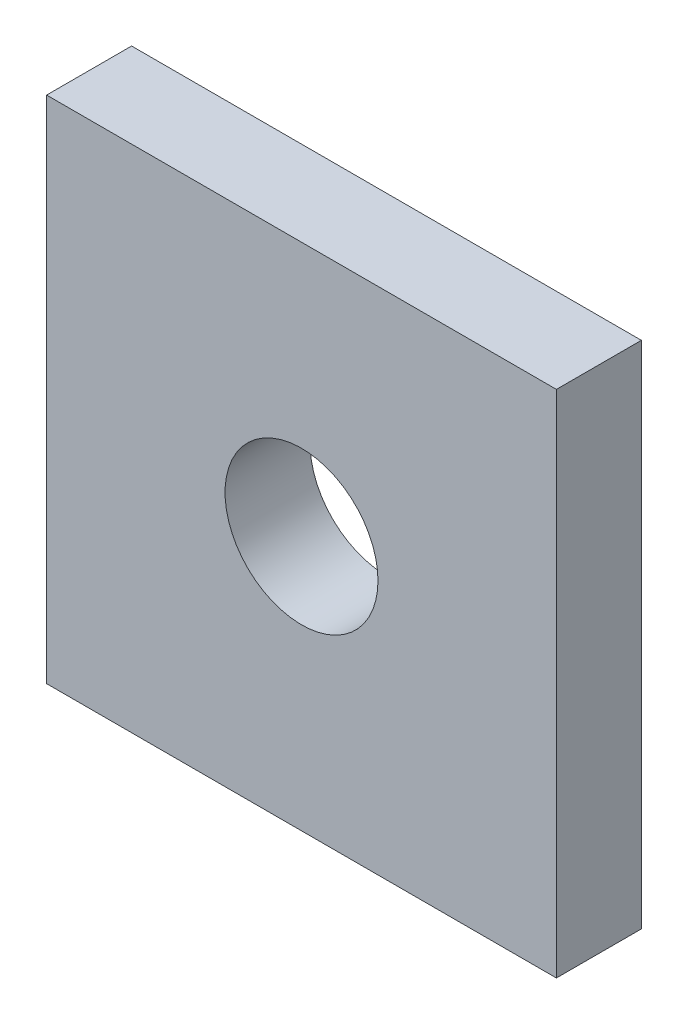
from build123d import *

# Parameters (mm, degrees)
SKETCH_1_W      = 30
SKETCH_1_H      = 30
SKETCH_1_R      = 4.5
EXTRUDE_1_DEPTH = 5


with BuildPart() as part:
    # 草图1 → 凸台-拉伸1 (new body)
    with BuildSketch(Plane.XY):
        Rectangle(SKETCH_1_W, SKETCH_1_H)
        Circle(SKETCH_1_R, mode=Mode.SUBTRACT)
    extrude(amount=EXTRUDE_1_DEPTH)


solid = part.part
